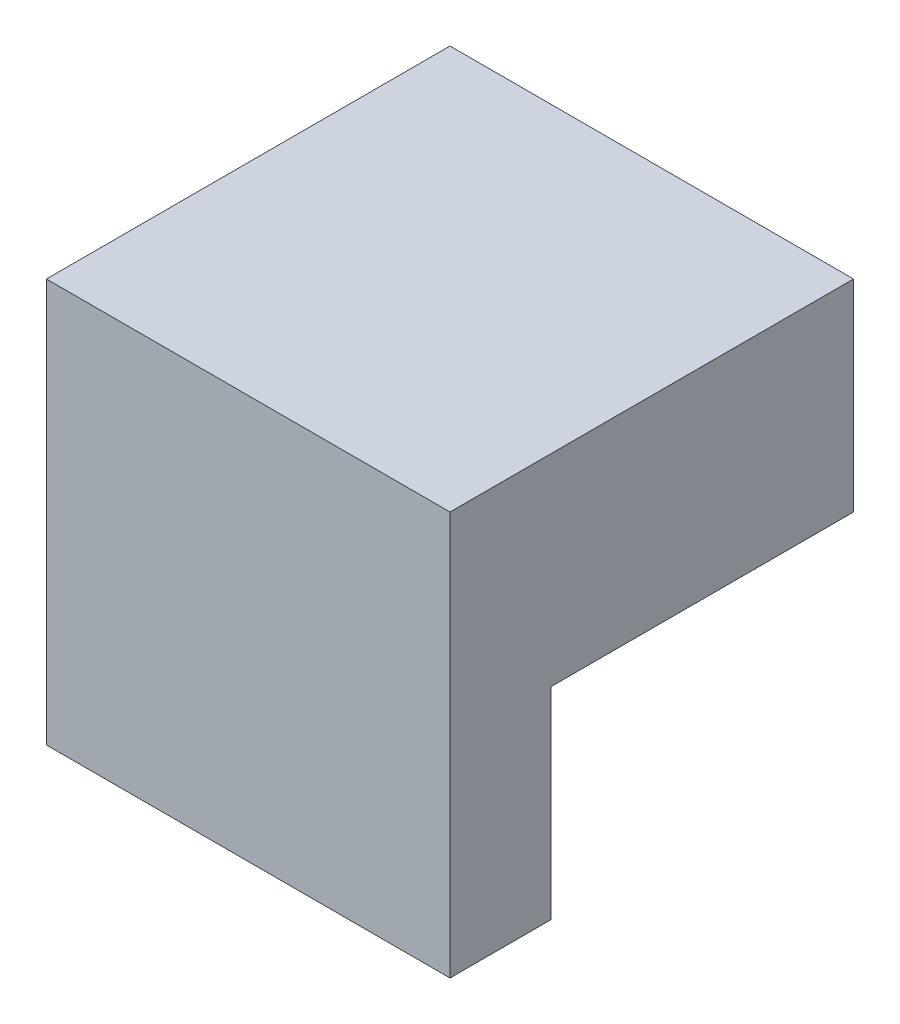
from build123d import *

# Parameters (mm, degrees)
SKETCH1_W           = 40
SKETCH1_H           = 40
BOSS_EXTRUDE1_DEPTH = 40
SKETCH2_W           = 10
SKETCH2_H           = 20
CUT_EXTRUDE1_DEPTH  = 40
CUT_EXTRUDE2_DEPTH  = 20


with BuildPart() as part:
    # Sketch1 → Boss-Extrude1 (new body)
    with BuildSketch(Plane.XY):
        with Locations((20, 20)):
            Rectangle(SKETCH1_W, SKETCH1_H)
    extrude(amount=BOSS_EXTRUDE1_DEPTH)

    # Sketch2 → Cut-Extrude1 (cut)
    with BuildSketch(Plane.ZY):
        with Locations((5, 10)):
            Rectangle(SKETCH2_W, SKETCH2_H)
    extrude(amount=-CUT_EXTRUDE1_DEPTH, mode=Mode.SUBTRACT)

    # Sketch3 → Cut-Extrude2 (cut)
    with BuildSketch(Plane.XZ):
        Polygon((0, 10), (0, 0), (40, 0), (40, 30), align=None)
    extrude(amount=-CUT_EXTRUDE2_DEPTH, mode=Mode.SUBTRACT)


solid = part.part
